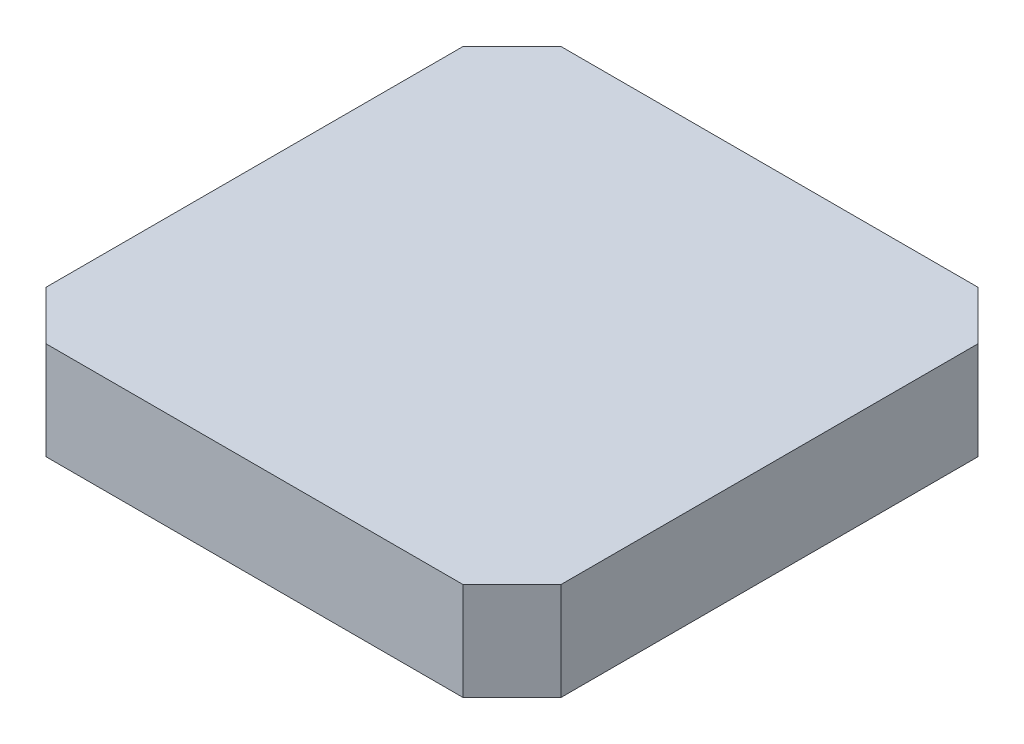
from build123d import *

# Parameters (mm, degrees)
SKETCH2_W           = 42.1
SKETCH2_H           = 42.1
BOSS_EXTRUDE1_DEPTH = 8
CHAMFER3_SIZE       = 4


with BuildPart() as part:
    # Sketch2 → Boss-Extrude1 (new body)
    with BuildSketch(Plane(origin=(0, 0, 0), x_dir=(1, 0, 0), z_dir=(0, 1, 0))):
        Rectangle(SKETCH2_W, SKETCH2_H)
    extrude(amount=BOSS_EXTRUDE1_DEPTH)

    # Chamfer3
    chamfer3_edges = [part.edges().sort_by_distance(p)[0] for p in [
        (21.05, 4, 21.05),
        (-21.05, 4, 21.05),
        (-21.05, 4, -21.05),
        (21.05, 4, -21.05),
    ]]
    chamfer(chamfer3_edges, length=CHAMFER3_SIZE)


solid = part.part
